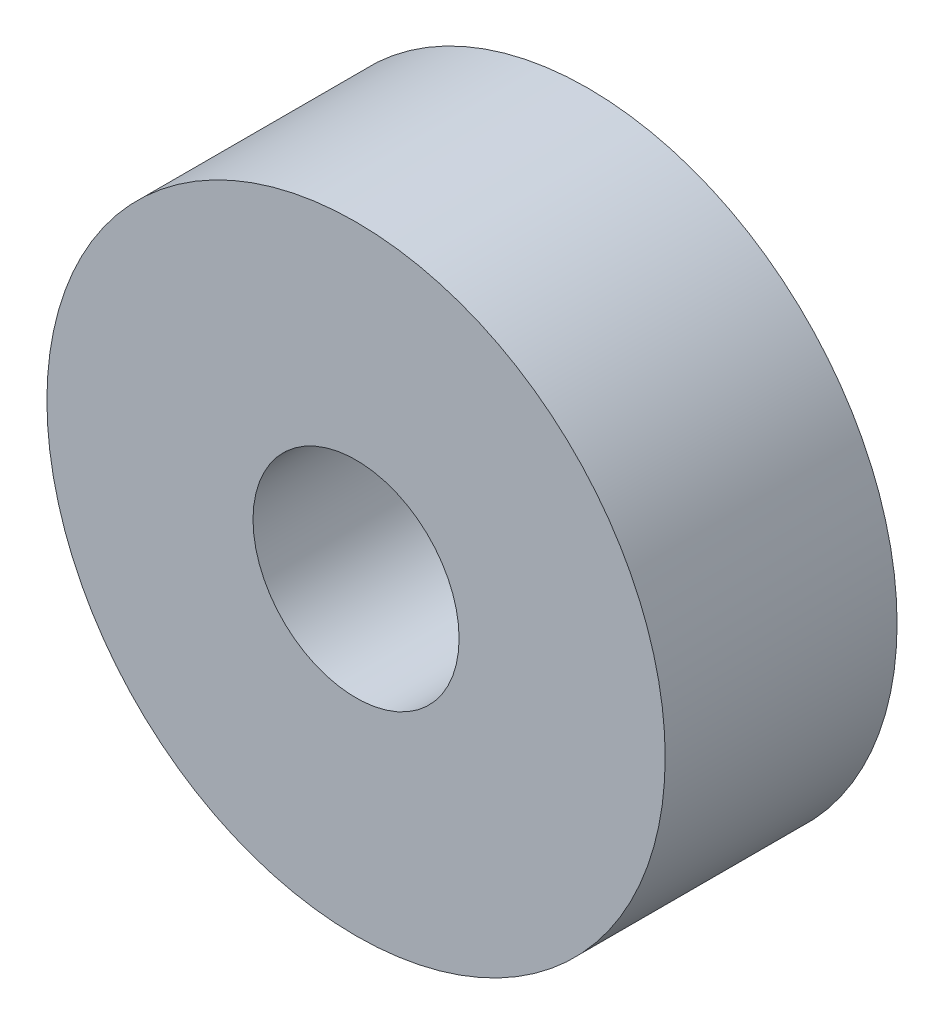
from build123d import *

# Parameters (mm, degrees)
SKETCH1_R           = 9.525
SKETCH1_R_2         = 3.175
BOSS_EXTRUDE1_DEPTH = 7.14502


with BuildPart() as part:
    # Sketch1 → Boss-Extrude1 (new body)
    with BuildSketch(Plane.XY):
        Circle(SKETCH1_R)
        Circle(SKETCH1_R_2, mode=Mode.SUBTRACT)
    extrude(amount=BOSS_EXTRUDE1_DEPTH)


solid = part.part
